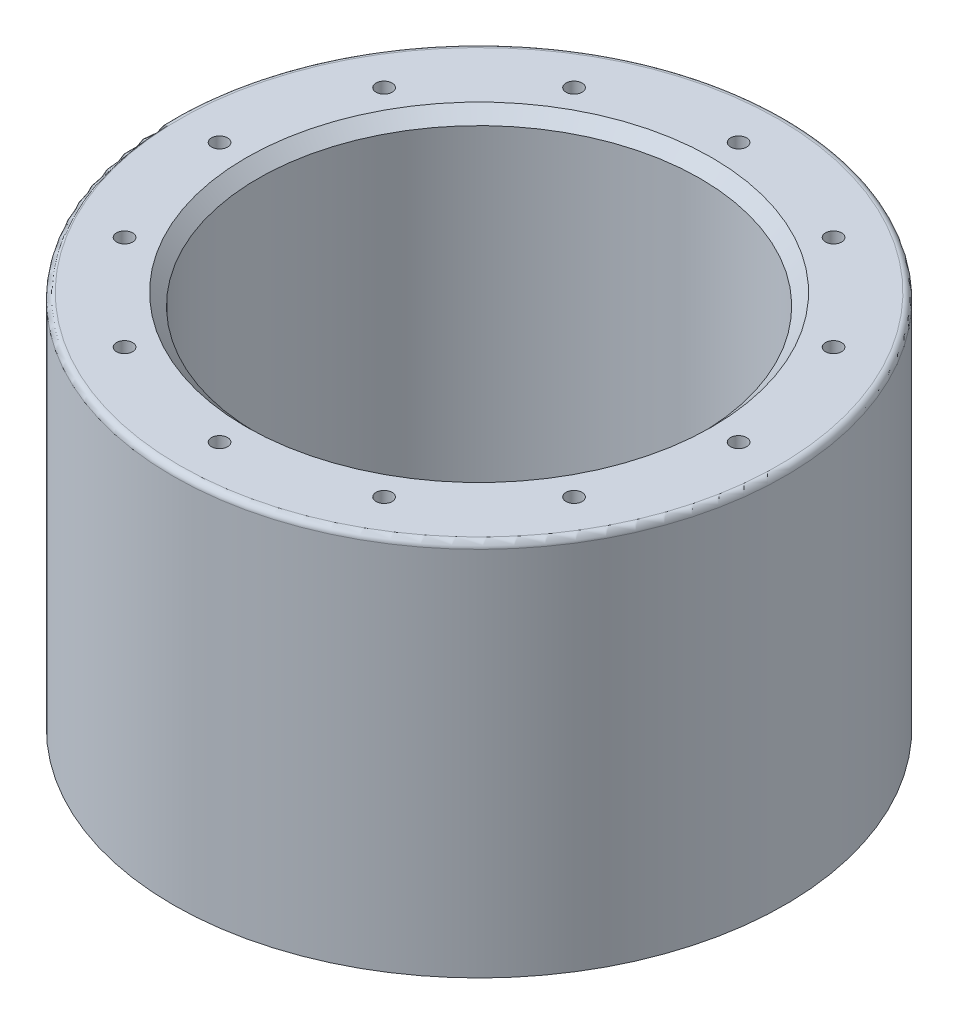
from build123d import *

# Parameters (mm, degrees)
SKETCH2_R                   = 97.278
SKETCH2_R_2                 = 70.278
BOSS_EXTRUDE2_DEPTH         = 120
SKETCH4_W                   = 7.62
SKETCH4_H                   = 4.2926
CHAMFER1_SIZE               = 3.8
F_1_4_20_TAPPED_HOLE1_D     = 5.1054
F_1_4_20_TAPPED_HOLE1_DEPTH = 25.4
F_1_4_20_TAPPED_HOLE1_TIP   = 1.533816902
F_1_4_20_TAPPED_HOLE2_D     = 5.1054
F_1_4_20_TAPPED_HOLE2_DEPTH = 25.4
F_1_4_20_TAPPED_HOLE2_TIP   = 1.533816902
FILLET1_R                   = 2


with BuildPart() as part:
    # Sketch2 → Boss-Extrude2 (new body)
    with BuildSketch(Plane(origin=(0, 0, 0), x_dir=(1, 0, 0), z_dir=(0, 1, 0))):
        Circle(SKETCH2_R)
        Circle(SKETCH2_R_2, mode=Mode.SUBTRACT)
    extrude(amount=BOSS_EXTRUDE2_DEPTH)

    # Sketch4 → Cut-Revolve1 (revolve, cut)
    with BuildSketch(Plane(origin=(0, 0, 0), x_dir=(0, 0, -1), z_dir=(1, 0, 0))):
        with Locations((89.281, 2.1463)):
            Rectangle(SKETCH4_W, SKETCH4_H)
    revolve(axis=Axis((0, 0, 0), (0, 1, 0)), mode=Mode.SUBTRACT)

    # Chamfer1
    chamfer1_edges = [part.edges().sort_by_distance(p)[0] for p in [
        (-70.278, 120, 0),
    ]]
    chamfer(chamfer1_edges, length=CHAMFER1_SIZE)

    # 1/4-20 Tapped Hole1
    with Locations(Plane(origin=(0, 0, 0), x_dir=(-1, 0, 0), z_dir=(0, -1, 0))):
        with Locations((0, 78.278), (-39.139, 67.790736557), (-67.790736557, 39.139), (-78.278, 0), (-67.790736557, -39.139), (-39.139, -67.790736557), (0, -78.278), (39.139, -67.790736557), (67.790736557, -39.139), (78.278, 0), (67.790736557, 39.139), (39.139, 67.790736557)):
            Hole(F_1_4_20_TAPPED_HOLE1_D / 2, depth=F_1_4_20_TAPPED_HOLE1_DEPTH)
            with Locations((0, 0, -(F_1_4_20_TAPPED_HOLE1_DEPTH + F_1_4_20_TAPPED_HOLE1_TIP / 2))):  # 118° drill point
                Cone(0, F_1_4_20_TAPPED_HOLE1_D / 2, F_1_4_20_TAPPED_HOLE1_TIP, mode=Mode.SUBTRACT)

    # 1/4-20 Tapped Hole2
    with Locations(Plane(origin=(0, 120, 0), x_dir=(1, 0, 0), z_dir=(0, 1, 0))):
        with Locations((-41.25, -71.447095812), (-71.447095812, -41.25), (-82.5, 0), (-71.447095812, 41.25), (-41.25, 71.447095812), (0, 82.5), (41.25, 71.447095812), (71.447095812, 41.25), (82.5, 0), (71.447095812, -41.25), (41.25, -71.447095812), (0, -82.5)):
            Hole(F_1_4_20_TAPPED_HOLE2_D / 2, depth=F_1_4_20_TAPPED_HOLE2_DEPTH)
            with Locations((0, 0, -(F_1_4_20_TAPPED_HOLE2_DEPTH + F_1_4_20_TAPPED_HOLE2_TIP / 2))):  # 118° drill point
                Cone(0, F_1_4_20_TAPPED_HOLE2_D / 2, F_1_4_20_TAPPED_HOLE2_TIP, mode=Mode.SUBTRACT)

    # Fillet1
    fillet1_edges = [part.edges().sort_by_distance(p)[0] for p in [
        (-97.278, 120, 0),
    ]]
    fillet(fillet1_edges, radius=FILLET1_R)


solid = part.part
